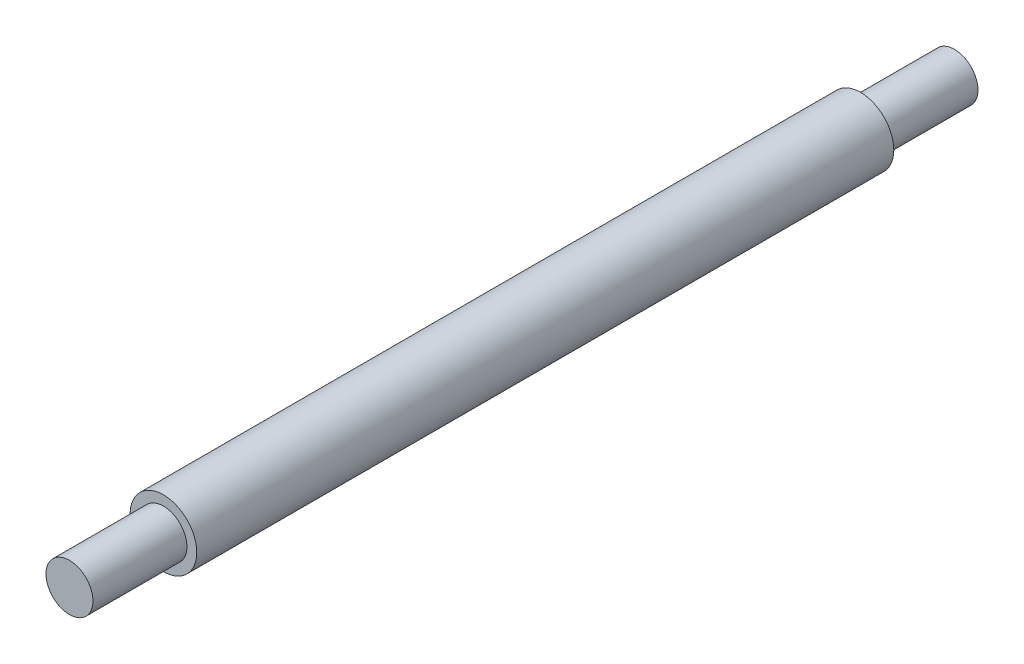
from build123d import *


with BuildPart() as part:
    # Sketch1 → Revolve2 (revolve)
    with BuildSketch(Plane(origin=(0, 0, 0), x_dir=(0, 0, -1), z_dir=(1, 0, 0)), mode=Mode.PRIVATE) as revolve2_sk:
        Polygon((0, 0), (0, 3), (12, 3), (12, 4.25), (101, 4.25), (101, 3), (113, 3), (113, 0), align=None)
    revolve(revolve2_sk.sketch.rotate(Axis((0, 0, 0), (0, 0, -1)), 90), axis=Axis((0, 0, 0), (0, 0, -1)))


solid = part.part
